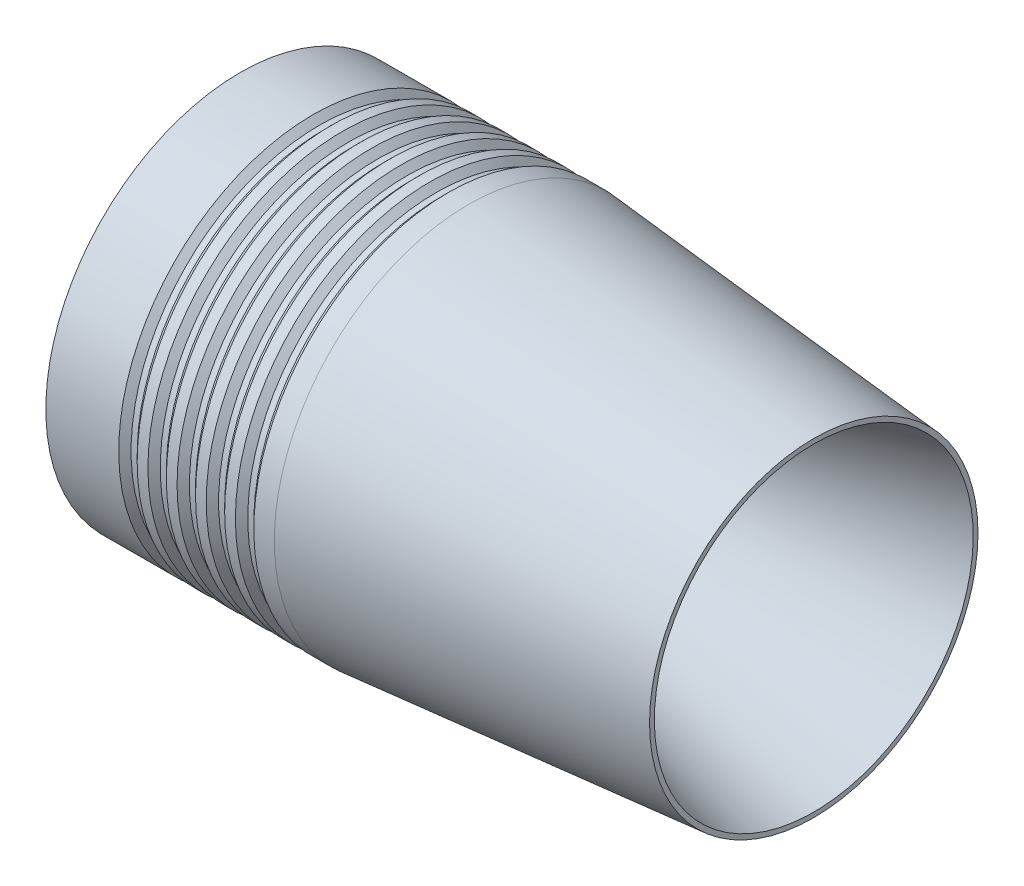
from build123d import *

# Parameters (mm, degrees)
SKETCH4_W       = 29.744523245
SKETCH4_H       = 12.7
SKETCH5_W       = 1.5875
SKETCH5_H       = 1.6129
LPATTERN1_COUNT = 5
LPATTERN1_PITCH = 7.62


with BuildPart() as part:
    # Sketch1 → Revolve1 (revolve)
    with BuildSketch(Plane.XY):
        with BuildLine():
            ThreePointArc((0, 17.653), (0.898160183, 17.712068298), (1.780848569, 17.888255676))
            Line((1.780848569, 17.888255676), (90.17, 41.656))
            Line((90.17, 41.656), (90.17, 42.91114721))
            Line((90.17, 42.91114721), (0, 50.8))
            Line((0, 50.8), (-59.69, 50.8))
            Line((-59.69, 50.8), (-59.69, 44.45))
            Line((-59.69, 44.45), (-72.39, 44.45))
            Line((-72.39, 44.45), (-72.39, 38.1))
            Line((-72.39, 38.1), (-59.69, 38.1))
            Line((-59.69, 38.1), (-9.310840107, 19.331058169))
            ThreePointArc((-9.310840107, 19.331058169), (-4.730423414, 18.075866931), (0, 17.653))
        make_face()
    revolve(axis=Axis((0, 0, 0), (-1, 0, 0)))

    # Sketch2 → Cut-Revolve2 (revolve, cut)
    with BuildSketch(Plane.XY):
        Polygon((25.4, 31.75), (0, 31.75), (-42.645476755, 31.75), (-50.8, 31.75), (-50.8, 0), (0, 0), (25.4, 0), align=None)
        Polygon((-42.645476755, 31.75), (0, 31.75), (25.4, 31.75), (-29.085538438, 35.56), (-42.645476755, 35.56), align=None)
    revolve(axis=Axis((-50.8, 0, 0), (1, 0, 0)), mode=Mode.SUBTRACT)

    # Sketch4 → Cut-Revolve4 (revolve, cut)
    with BuildSketch(Plane.XY):
        with Locations((-57.517738378, 38.1)):
            Rectangle(SKETCH4_W, SKETCH4_H)
    revolve(axis=Axis((0, 0, 0), (-1, 0, 0)), mode=Mode.SUBTRACT)

    # Sketch5 → Cut-Revolve5 (revolve, cut)
    with BuildSketch(Plane.XY):
        Polygon((-37.4396, 50.8), (-37.4396, 49.1871), (-35.8267, 50.8), align=None)
        with Locations((-38.23335, 49.99355)):
            Rectangle(SKETCH5_W, SKETCH5_H)
        Polygon((-40.64, 50.8), (-39.0271, 49.1871), (-39.0271, 50.8), align=None)
    cut_revolve5 = revolve(axis=Axis((0, 0, 0), (-1, 0, 0)), mode=Mode.SUBTRACT)

    # LPattern1: Cut-Revolve5 ×5
    with Locations(*[(i * LPATTERN1_PITCH, 0, 0) for i in range(1, LPATTERN1_COUNT)]):
        add(cut_revolve5, mode=Mode.SUBTRACT)


solid = part.part
